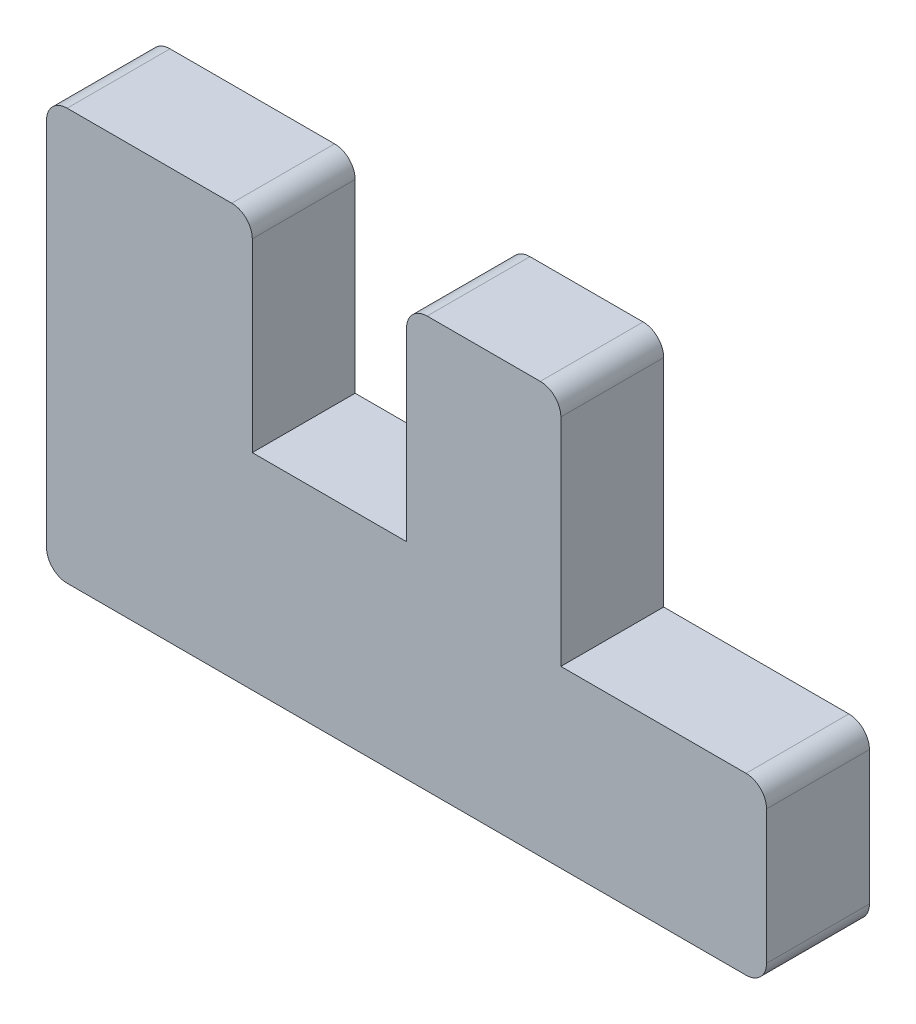
from build123d import *

# Parameters (mm, degrees)
BOSS_EXTRUDE1_DEPTH = 12.7
FILLET1_R           = 2.54


with BuildPart() as part:
    # Sketch1 → Boss-Extrude1 (new body)
    with BuildSketch(Plane.XY):
        Polygon((0, 0), (0, 50.8), (25.4, 50.8), (25.4, 25.4), (44.45, 25.4), (44.45, 50.8), (63.5, 50.8), (63.5, 21.59), (88.9, 21.59), (88.9, 0), align=None)
    extrude(amount=BOSS_EXTRUDE1_DEPTH)

    # Fillet1
    fillet1_edges = [part.edges().sort_by_distance(p)[0] for p in [
        (0, 0, 6.35),
        (0, 50.8, 6.35),
        (25.4, 50.8, 6.35),
        (44.45, 50.8, 6.35),
        (63.5, 50.8, 6.35),
        (88.9, 21.59, 6.35),
        (88.9, 0, 6.35),
    ]]
    fillet(fillet1_edges, radius=FILLET1_R)


solid = part.part
